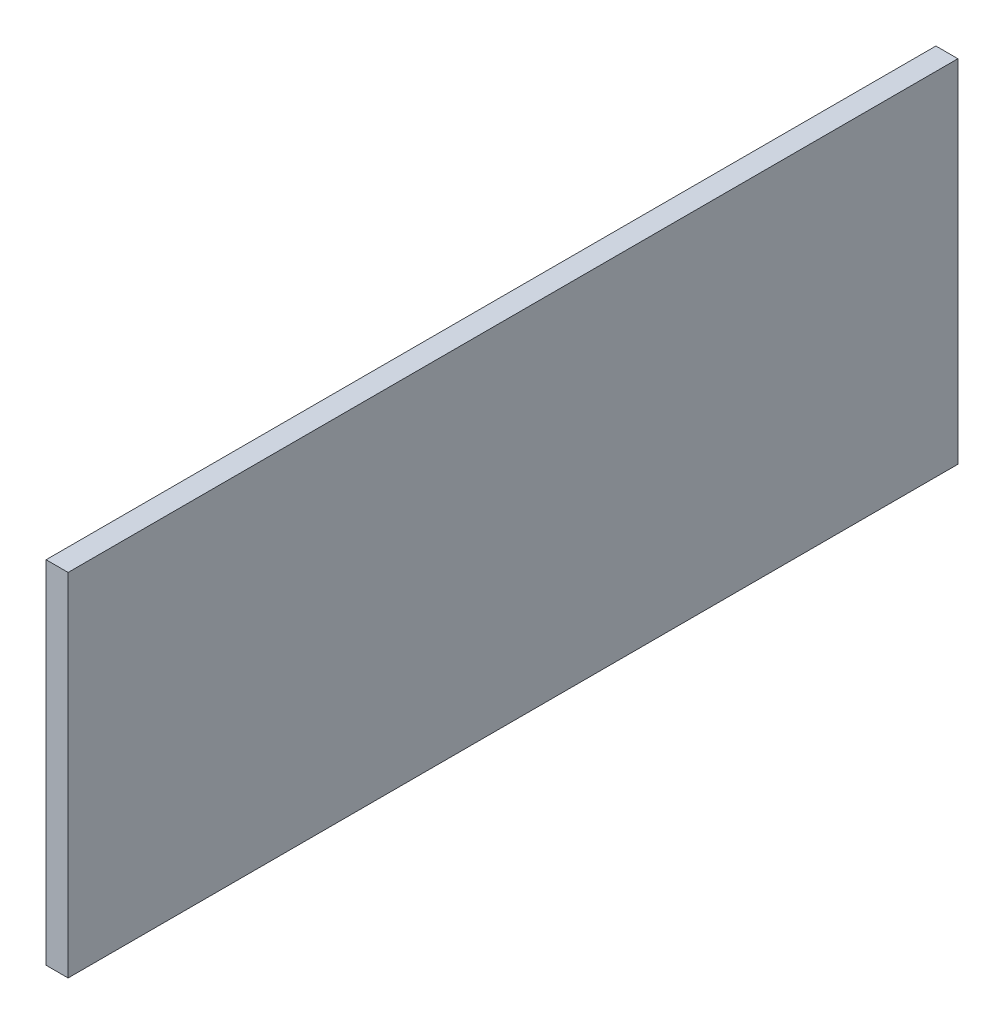
from build123d import *

# Parameters (mm, degrees)
SKETCH1_W           = 482.6
SKETCH1_H           = 190.5
BOSS_EXTRUDE1_DEPTH = 11.938


with BuildPart() as part:
    # Sketch1 → Boss-Extrude1 (new body)
    with BuildSketch(Plane(origin=(0, 0, 0), x_dir=(0, 0, -1), z_dir=(1, 0, 0))):
        Rectangle(SKETCH1_W, SKETCH1_H)
    extrude(amount=BOSS_EXTRUDE1_DEPTH)


solid = part.part
